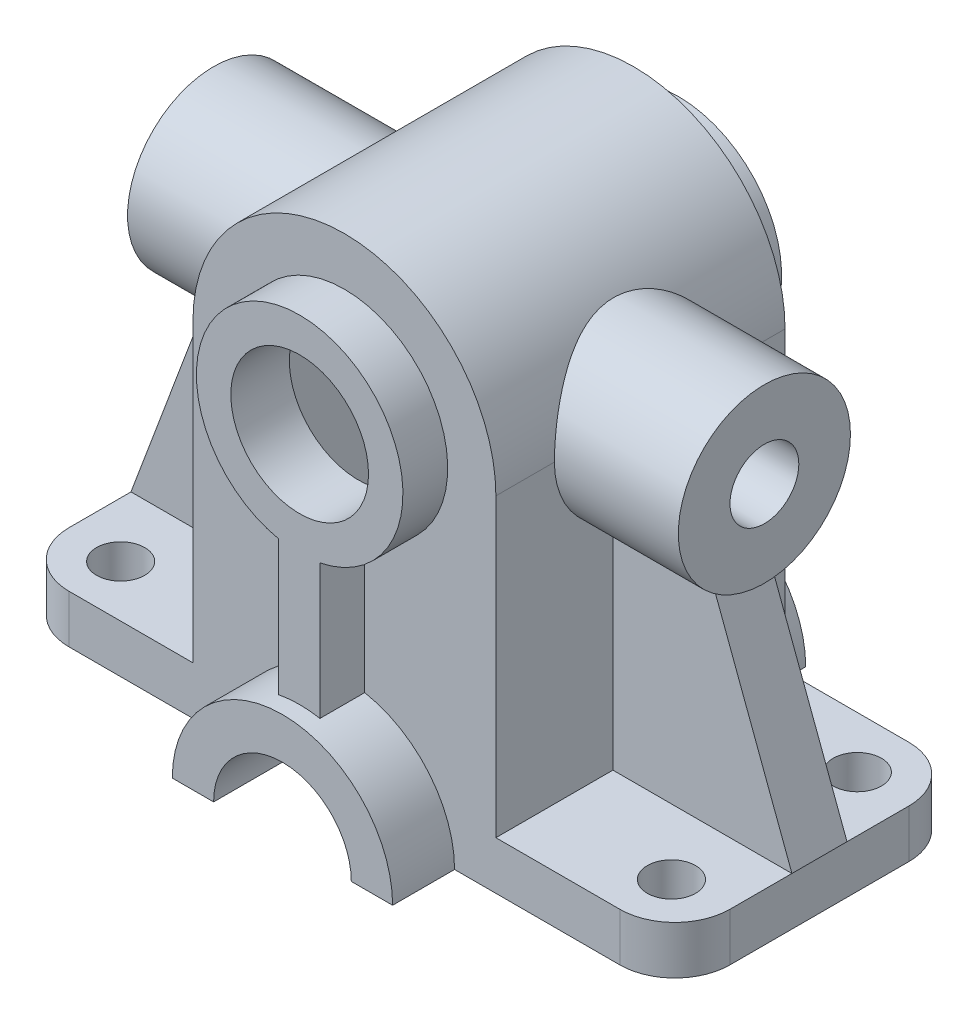
from build123d import *

# Parameters (mm, degrees)
SKETCH1_R           = 15
SKETCH1_R_2         = 10
BOSS_EXTRUDE1_DEPTH = 21
SKETCH2_R           = 3.5
CUT_EXTRUDE1_DEPTH  = 60
FILLET1_R           = 8
SKETCH5_R           = 10
BOSS_EXTRUDE2_DEPTH = 6.5
BOSS_EXTRUDE3_DEPTH = 9
SKETCH6_R           = 12.5
BOSS_EXTRUDE4_DEPTH = 40
BOSS_EXTRUDE5_DEPTH = 4
SKETCH1_3_R         = 10
CUT_EXTRUDE2_DEPTH  = 21
SKETCH10_W          = 19
SKETCH10_H          = 38
SKETCH11_W          = 38
SKETCH11_H          = 38
CUT_EXTRUDE3_DEPTH  = 51


with BuildPart() as part:
    # Sketch1 → Boss-Extrude1 (new body, symmetric)
    with BuildSketch(Plane.XY):
        with BuildLine():
            ThreePointArc((22, 0), (0, 22), (-22, 0))
            Line((-22, 0), (-22, -43))
            Line((-22, -43), (-48, -43))
            Line((-48, -43), (-48, -50))
            Line((-48, -50), (-16, -50))
            ThreePointArc((-16, -50), (0, -34), (16, -50))
            Line((16, -50), (48, -50))
            Line((48, -50), (48, -43))
            Line((48, -43), (22, -43))
            Line((22, -43), (22, 0))
        make_face()
        Circle(SKETCH1_R, mode=Mode.SUBTRACT)
        with BuildLine():
            ThreePointArc((16, -50), (0, -34), (-16, -50))
            Line((-16, -50), (-10, -50))
            ThreePointArc((-10, -50), (0, -40), (10, -50))
            Line((10, -50), (16, -50))
        make_face()
        Circle(SKETCH1_R)
        Circle(SKETCH1_R_2, mode=Mode.SUBTRACT)
    extrude(amount=BOSS_EXTRUDE1_DEPTH, both=True)

    # Sketch2 → Cut-Extrude1 (cut)
    with BuildSketch(Plane(origin=(0, -43, 0), x_dir=(1, 0, 0), z_dir=(0, 1, 0))):
        with Locations((40, 13.5)):
            Circle(SKETCH2_R)
        with Locations((40, -13.5)):
            Circle(SKETCH2_R)
    cut_extrude1 = extrude(amount=-CUT_EXTRUDE1_DEPTH, mode=Mode.SUBTRACT)

    # Mirror1: Cut-Extrude1 across plane
    add(cut_extrude1.mirror(Plane(origin=(0, 0, 0), x_dir=(0, 0, 1), z_dir=(1, 0, 0))), mode=Mode.SUBTRACT)

    # Fillet1
    fillet1_edges = [part.edges().sort_by_distance(p)[0] for p in [
        (-48, -46.5, -21),
        (48, -46.5, -21),
        (48, -46.5, 21),
        (-48, -46.5, 21),
    ]]
    fillet(fillet1_edges, radius=FILLET1_R)

    # Sketch5 → Boss-Extrude2 (add)
    with BuildSketch(Plane.XY.offset(21)):
        with BuildLine():
            Line((-3.053517872, -14.68591259), (-3.053517872, -34.294076639))
            ThreePointArc((-3.053517872, -34.294076639), (-0.054484182, -34.000092767), (2.946482128, -34.273644953))
            Line((2.946482128, -34.273644953), (2.946482128, -14.707761321))
            ThreePointArc((2.946482128, -14.707761321), (0.054621464, 14.99990055), (-3.053517872, -14.68591259))
        make_face()
        Circle(SKETCH5_R, mode=Mode.SUBTRACT)
    boss_extrude2 = extrude(amount=BOSS_EXTRUDE2_DEPTH)

    # Sketch5_3 → Boss-Extrude3 (add)
    with BuildSketch(Plane.XY.offset(21)):
        with BuildLine():
            ThreePointArc((-3.053517872, -34.294076639), (-12.346179286, -39.822974058), (-16, -50))
            Line((-16, -50), (-10, -50))
            ThreePointArc((-10, -50), (0, -40), (10, -50))
            Line((10, -50), (16, -50))
            ThreePointArc((16, -50), (12.311452271, -39.780991096), (2.946482128, -34.273644953))
            ThreePointArc((2.946482128, -34.273644953), (-0.054484182, -34.000092767), (-3.053517872, -34.294076639))
        make_face()
    boss_extrude3 = extrude(amount=BOSS_EXTRUDE3_DEPTH)

    # Mirror2: Boss-Extrude2, Boss-Extrude3 across plane
    add(boss_extrude2.mirror(Plane.XY))
    add(boss_extrude3.mirror(Plane.XY))

    # Sketch6 → Boss-Extrude4 (add)
    with BuildSketch(Plane(origin=(0, 0, 0), x_dir=(0, 0, -1), z_dir=(1, 0, 0))):
        Circle(SKETCH6_R)
    boss_extrude4 = extrude(amount=BOSS_EXTRUDE4_DEPTH)

    # Sketch7 → Boss-Extrude5 (add, symmetric)
    with BuildSketch(Plane.XY):
        Polygon((22, -43), (48, -43), (36, -10.955283754), (22, -10.955283754), align=None)
    boss_extrude5 = extrude(amount=BOSS_EXTRUDE5_DEPTH, both=True)

    # Sketch1_3 → Cut-Extrude2 (cut, symmetric)
    with BuildSketch(Plane.XY):
        Circle(SKETCH1_3_R)
    cut_extrude2 = extrude(amount=CUT_EXTRUDE2_DEPTH, both=True, mode=Mode.SUBTRACT)

    # Sketch8 → Cut-Revolve1 (revolve, cut)
    with BuildSketch(Plane(origin=(0, 0, 0), x_dir=(1, 0, 0), z_dir=(0, 1, 0))):
        Polygon((40, 0), (22, 0), (23.87378357, 4.5), (24.87378357, 4.5), (24.87378357, 5), (40, 5), align=None)
    cut_revolve1 = revolve(axis=Axis((40, 0, 0), (-1, 0, 0)), mode=Mode.SUBTRACT)

    # Mirror4: Boss-Extrude4, Boss-Extrude5, Cut-Extrude2, Cut-Revolve1 across plane
    add(boss_extrude4.mirror(Plane(origin=(0, 0, 0), x_dir=(0, 0, 1), z_dir=(1, 0, 0))))
    add(boss_extrude5.mirror(Plane(origin=(0, 0, 0), x_dir=(0, 0, 1), z_dir=(1, 0, 0))))
    add(cut_extrude2.mirror(Plane(origin=(0, 0, 0), x_dir=(0, 0, 1), z_dir=(1, 0, 0))), mode=Mode.SUBTRACT)
    add(cut_revolve1.mirror(Plane(origin=(0, 0, 0), x_dir=(0, 0, 1), z_dir=(1, 0, 0))), mode=Mode.SUBTRACT)

    # Sketch10 → Cut-Revolve2 (revolve, cut)
    with BuildSketch(Plane(origin=(0, 0, 0), x_dir=(1, 0, 0), z_dir=(0, 1, 0))):
        with Locations((-9.5, 0)):
            Rectangle(SKETCH10_W, SKETCH10_H)
    revolve(axis=Axis((0, 0, -19), (0, 0, 1)), mode=Mode.SUBTRACT)

    # Sketch11 → Cut-Extrude3 (cut, through all)
    with BuildSketch(Plane(origin=(0, 0, 0), x_dir=(1, 0, 0), z_dir=(0, 1, 0))):
        Rectangle(SKETCH11_W, SKETCH11_H)
    extrude(amount=-CUT_EXTRUDE3_DEPTH, mode=Mode.SUBTRACT)


solid = part.part
